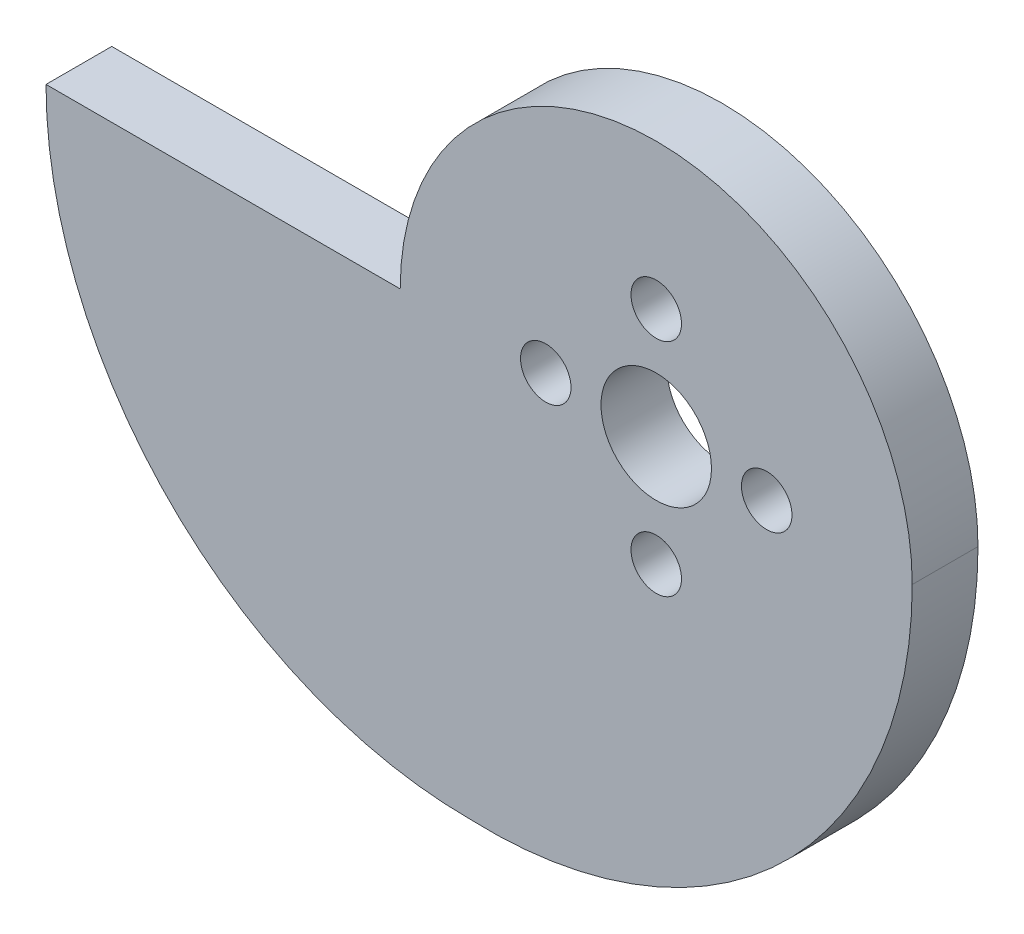
from build123d import *

# Parameters (mm, degrees)
SKETCH1_R             = 4
BOSS_EXTRUDE1_DEPTH   = 4.7625
F_6_CLEARANCE_HOLE1_D = 3.6576


with BuildPart() as part:
    # Sketch1 → Boss-Extrude1 (new body)
    with BuildSketch(Plane.XY):
        with BuildLine():
            Line((-44.196, 0), (-18.542, 0))
            ThreePointArc((-18.542, 0), (0, 18.542), (18.542, 0))
            ThreePointArc((18.542, 0), (9.088190436, -22.185776818), (-13.462, -30.734))
            ThreePointArc((-13.462, -30.734), (-35.194219813, -21.732219813), (-44.196, 0))
        make_face()
        Circle(SKETCH1_R, mode=Mode.SUBTRACT)
    extrude(amount=BOSS_EXTRUDE1_DEPTH)

    # 6 Clearance Hole1 (through all)
    with Locations(Plane.XY.offset(4.7625)):
        with Locations((0, 8), (8, 0), (0, -8), (-8, 0)):
            Hole(F_6_CLEARANCE_HOLE1_D / 2)


solid = part.part
